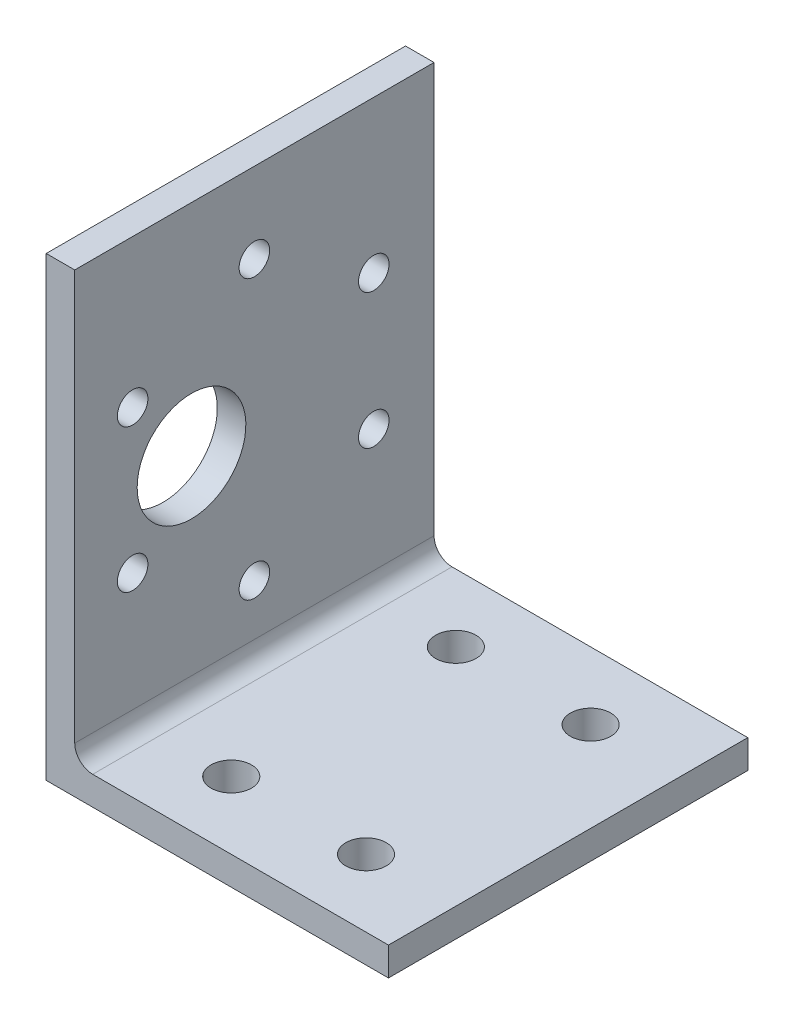
from build123d import *

# Parameters (mm, degrees)
BOSS_EXTRUDE1_DEPTH  = 20
FILLET1_R            = 2
M3_CLEARANCE_HOLE1_D = 3.4
SKETCH6_R            = 6.05
CUT_EXTRUDE1_DEPTH   = 39.1
M4_CLEARANCE_HOLE1_D = 4.5


with BuildPart() as part:
    # Sketch1 → Boss-Extrude1 (new body, symmetric)
    with BuildSketch(Plane.XY):
        Polygon((0, 0), (0, 50.8), (3.175, 50.8), (3.175, 3.175), (38.1, 3.175), (38.1, 0), align=None)
    extrude(amount=BOSS_EXTRUDE1_DEPTH, both=True)

    # Fillet1
    fillet1_edges = [part.edges().sort_by_distance(p)[0] for p in [
        (3.175, 3.175, 0),
    ]]
    fillet(fillet1_edges, radius=FILLET1_R)

    # M3 Clearance Hole1 (through all)
    with Locations(Plane.ZY):
        with Locations((0, 41.847738991), (13.553804618, 34.328139243), (-13.289066718, 18.830400251), (0, 10.852261009), (-13.289066718, 33.869599749), (13.553804618, 18.371860757)):
            Hole(M3_CLEARANCE_HOLE1_D / 2)

    # Sketch6 → Cut-Extrude1 (cut, through all)
    with BuildSketch(Plane.ZY):
        with Locations((7, 26.35)):
            Circle(SKETCH6_R)
    extrude(amount=-CUT_EXTRUDE1_DEPTH, mode=Mode.SUBTRACT)

    # M4 Clearance Hole1 (through all)
    with Locations(Plane(origin=(0, 3.175, 0), x_dir=(1, 0, 0), z_dir=(0, 1, 0))):
        with Locations((13.1, -12.5), (28.1, -12.5), (28.1, 12.5), (13.1, 12.5)):
            Hole(M4_CLEARANCE_HOLE1_D / 2)


solid = part.part
